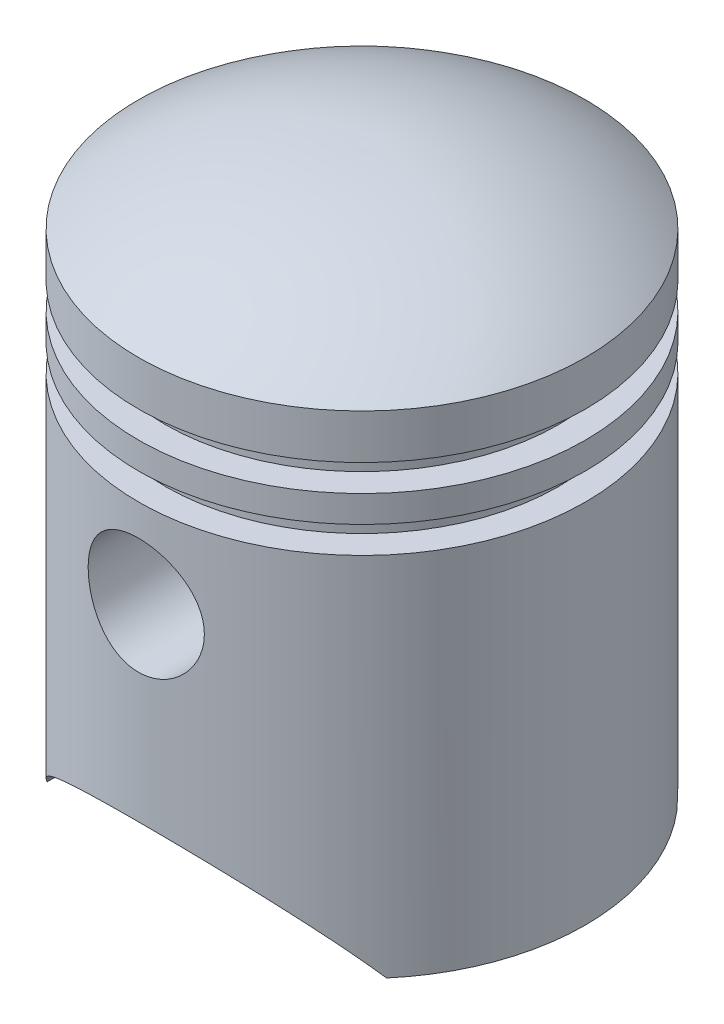
from build123d import *

# Parameters (mm, degrees)
SKETCH2_R               = 6.5
CUT_EXTRUDE2_DEPTH      = 26.0000001
CUT_EXTRUDE2_DEPTH_BACK = 26.0000001
BOSS_EXTRUDE1_START     = 12
SKETCH3_R               = 7.5
SKETCH3_R_2             = 6.5
BOSS_EXTRUDE1_DEPTH     = 11


with BuildPart() as part:
    # Sketch1 → Revolve9 (revolve)
    with BuildSketch(Plane.XY):
        with BuildLine():
            Line((-23, -31.5), (-23, 7.5))
            Line((-23, 7.5), (-20, 7.5))
            Line((-20, 7.5), (-20, 20.5))
            Line((-20, 20.5), (-23, 20.5))
            Line((-23, 20.5), (-23, 22.484511145))
            ThreePointArc((-23, 22.484511145), (-12.093024708, 27.851979987), (-0.04919363, 29.500605095))
            Line((-0.04919363, 29.500605095), (0, 29.500605095))
            Line((0, 29.500605095), (0, 31.5))
            ThreePointArc((0, 31.5), (-13.174901691, 29.609067785), (-25, 23.5))
            Line((-25, 23.5), (-25, 18.5))
            Line((-25, 18.5), (-22, 18.5))
            Line((-22, 18.5), (-22, 15.5))
            Line((-22, 15.5), (-25, 15.5))
            Line((-25, 15.5), (-25, 12.5))
            Line((-25, 12.5), (-22, 12.5))
            Line((-22, 12.5), (-22, 9.5))
            Line((-22, 9.5), (-25, 9.5))
            Line((-25, 9.5), (-25, -31.5))
            Line((-25, -31.5), (-23, -31.5))
        make_face()
    revolve(axis=Axis((0, -31.5, 0), (0, 1, 0)))

    # Sketch2 → Cut-Extrude2 (cut, two sides)
    with BuildSketch(Plane.XY) as cut_extrude2_sk:
        with Locations((0, -0.5)):
            Circle(SKETCH2_R)
        with BuildLine():
            Line((-19, -31.5), (19, -31.5))
            ThreePointArc((19, -31.5), (0, -21.5), (-19, -31.5))
        make_face()
    extrude(amount=CUT_EXTRUDE2_DEPTH, mode=Mode.SUBTRACT)
    extrude(cut_extrude2_sk.sketch, amount=-CUT_EXTRUDE2_DEPTH_BACK, mode=Mode.SUBTRACT)

    # Sketch3 → Boss-Extrude1 (add)
    with BuildSketch(Plane.XY.offset(BOSS_EXTRUDE1_START)):
        with Locations((0, -0.5)):
            Circle(SKETCH3_R)
        with Locations((0, -0.5)):
            Circle(SKETCH3_R_2, mode=Mode.SUBTRACT)
    boss_extrude1 = extrude(amount=BOSS_EXTRUDE1_DEPTH)

    # Mirror1: Boss-Extrude1 across plane
    add(boss_extrude1.mirror(Plane.XY))


solid = part.part
